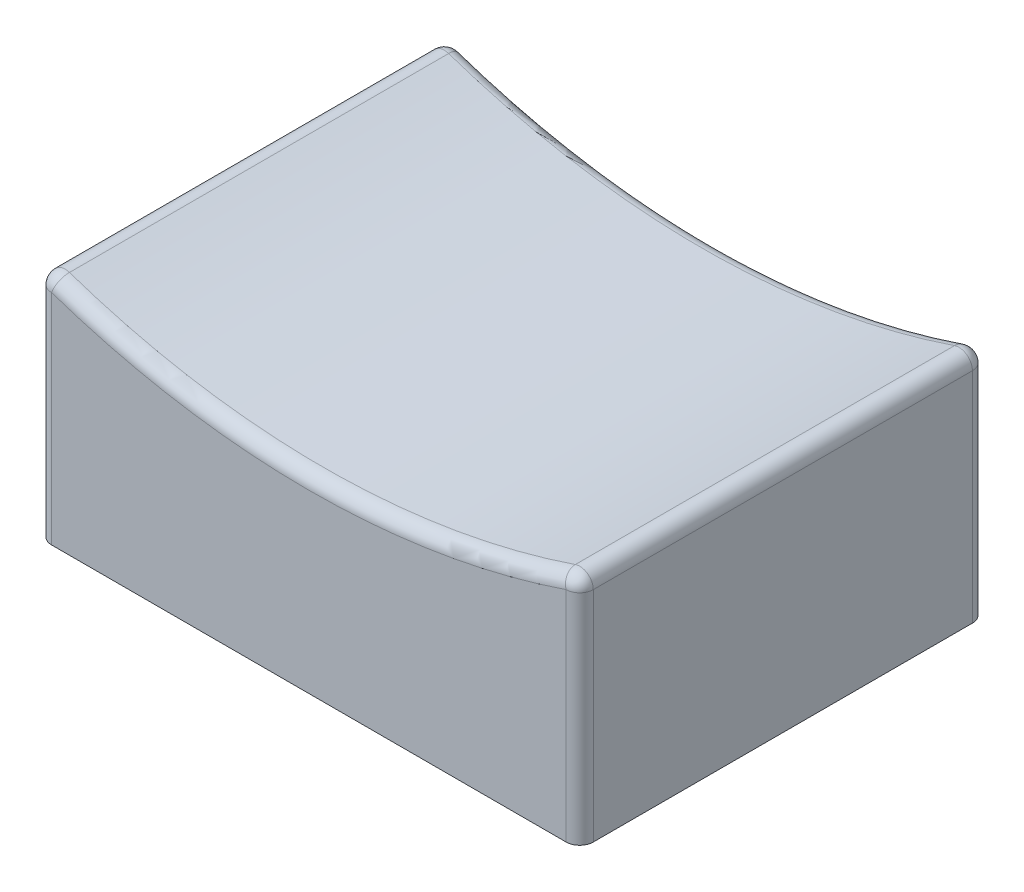
from build123d import *

# Parameters (mm, degrees)
BOSS_EXTRUDE1_DEPTH = 15
FILLET1_R           = 0.5


with BuildPart() as part:
    # Sketch1 → Boss-Extrude1 (new body)
    with BuildSketch(Plane.XY):
        with BuildLine():
            Line((0, 0), (20, 0))
            Line((20, 0), (20, 8.778684822))
            ThreePointArc((20, 8.778684822), (10, 7), (0, 8.778684822))
            Line((0, 8.778684822), (0, 0))
        make_face()
    extrude(amount=BOSS_EXTRUDE1_DEPTH)

    # Fillet1
    fillet1_edges = [part.edges().sort_by_distance(p)[0] for p in [
        (20, 4.389342411, 15),
        (10, 7, 15),
        (0, 4.389342411, 15),
        (10, 7, 0),
        (20, 4.389342411, 0),
        (0, 4.389342411, 0),
        (0, 8.778684822, 7.5),
        (20, 8.778684822, 7.5),
    ]]
    fillet(fillet1_edges, radius=FILLET1_R)


solid = part.part
